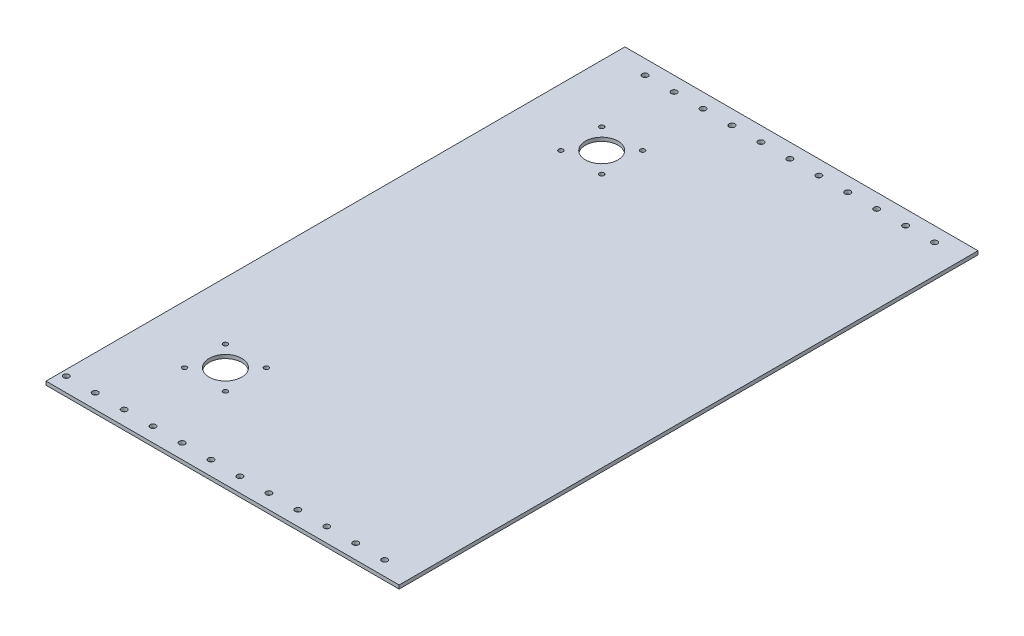
from build123d import *

# Parameters (mm, degrees)
SKETCH1_W               = 406.4
SKETCH1_H               = 508
BOSS_EXTRUDE1_DEPTH     = 3.175
SKETCH2_R               = 14.2875
CUT_EXTRUDE1_DEPTH      = 3.175
SKETCH3_R               = 2.4892
CUT_EXTRUDE2_DEPTH      = 1
CUT_EXTRUDE2_DEPTH_BACK = 4.175
SKETCH4_R               = 2.0193
CUT_EXTRUDE3_DEPTH      = 1
CUT_EXTRUDE3_DEPTH_BACK = 4.175
SKETCH5_W               = 508
SKETCH5_H               = 3.175
CUT_EXTRUDE4_DEPTH      = 96.52


with BuildPart() as part:
    # Sketch1 → Boss-Extrude1 (new body)
    with BuildSketch(Plane(origin=(0, 0, 0), x_dir=(1, 0, 0), z_dir=(0, 1, 0))):
        with Locations((203.2, 254)):
            Rectangle(SKETCH1_W, SKETCH1_H)
    extrude(amount=BOSS_EXTRUDE1_DEPTH)

    # Sketch2 → Cut-Extrude1 (cut)
    with BuildSketch(Plane(origin=(0, 3.175, 0), x_dir=(1, 0, 0), z_dir=(0, 1, 0))):
        with Locations((50.8, 419.1)):
            Circle(SKETCH2_R)
        with Locations((165.1, 419.1)):
            Circle(SKETCH2_R)
        with Locations((50.8, 88.9)):
            Circle(SKETCH2_R)
        with Locations((165.1, 88.9)):
            Circle(SKETCH2_R)
    extrude(amount=-CUT_EXTRUDE1_DEPTH, mode=Mode.SUBTRACT)

    # Sketch3 → Cut-Extrude2 (cut, two sides)
    with BuildSketch(Plane(origin=(0, 3.175, 0), x_dir=(1, 0, 0), z_dir=(0, 1, 0))) as cut_extrude2_sk:
        with Locations((38.1, 12.7)):
            Circle(SKETCH3_R)
        with Locations((63.5, 12.7)):
            Circle(SKETCH3_R)
        with Locations((127, 12.7)):
            Circle(SKETCH3_R)
        with Locations((152.4, 12.7)):
            Circle(SKETCH3_R)
        with Locations((177.8, 12.7)):
            Circle(SKETCH3_R)
        with Locations((203.2, 12.7)):
            Circle(SKETCH3_R)
        with Locations((228.6, 12.7)):
            Circle(SKETCH3_R)
        with Locations((254, 12.7)):
            Circle(SKETCH3_R)
        with Locations((279.4, 12.7)):
            Circle(SKETCH3_R)
        with Locations((304.8, 12.7)):
            Circle(SKETCH3_R)
        with Locations((330.2, 12.7)):
            Circle(SKETCH3_R)
        with Locations((355.6, 12.7)):
            Circle(SKETCH3_R)
        with Locations((381, 12.7)):
            Circle(SKETCH3_R)
        with Locations((381, 495.3)):
            Circle(SKETCH3_R)
        with Locations((355.6, 495.3)):
            Circle(SKETCH3_R)
        with Locations((330.2, 495.3)):
            Circle(SKETCH3_R)
        with Locations((304.8, 495.3)):
            Circle(SKETCH3_R)
        with Locations((279.4, 495.3)):
            Circle(SKETCH3_R)
        with Locations((254, 495.3)):
            Circle(SKETCH3_R)
        with Locations((228.6, 495.3)):
            Circle(SKETCH3_R)
        with Locations((203.2, 495.3)):
            Circle(SKETCH3_R)
        with Locations((177.8, 495.3)):
            Circle(SKETCH3_R)
        with Locations((152.4, 495.3)):
            Circle(SKETCH3_R)
        with Locations((127, 495.3)):
            Circle(SKETCH3_R)
        with Locations((63.5, 495.3)):
            Circle(SKETCH3_R)
        with Locations((38.1, 495.3)):
            Circle(SKETCH3_R)
        with Locations((101.6, 12.7)):
            Circle(SKETCH3_R)
    extrude(amount=CUT_EXTRUDE2_DEPTH, mode=Mode.SUBTRACT)
    extrude(cut_extrude2_sk.sketch, amount=-CUT_EXTRUDE2_DEPTH_BACK, mode=Mode.SUBTRACT)

    # Sketch4 → Cut-Extrude3 (cut, two sides)
    with BuildSketch(Plane(origin=(0, 3.175, 0), x_dir=(1, 0, 0), z_dir=(0, 1, 0))) as cut_extrude3_sk:
        with Locations((76.2, 419.1)):
            Circle(SKETCH4_R)
        with Locations((25.4, 419.1)):
            Circle(SKETCH4_R)
        with Locations((38.1, 441.097045256)):
            Circle(SKETCH4_R)
        with Locations((63.5, 441.097045256)):
            Circle(SKETCH4_R)
        with Locations((63.5, 397.102954744)):
            Circle(SKETCH4_R)
        with Locations((38.1, 397.102954744)):
            Circle(SKETCH4_R)
        with Locations((147.139487788, 437.060512212)):
            Circle(SKETCH4_R)
        with Locations((183.060512212, 437.060512212)):
            Circle(SKETCH4_R)
        with Locations((183.060512212, 401.139487788)):
            Circle(SKETCH4_R)
        with Locations((147.139487788, 401.139487788)):
            Circle(SKETCH4_R)
        with Locations((147.139487788, 106.860512212)):
            Circle(SKETCH4_R)
        with Locations((183.060512212, 106.860512212)):
            Circle(SKETCH4_R)
        with Locations((183.060512212, 70.939487788)):
            Circle(SKETCH4_R)
        with Locations((147.139487788, 70.939487788)):
            Circle(SKETCH4_R)
        with Locations((38.1, 110.897045256)):
            Circle(SKETCH4_R)
        with Locations((63.5, 110.897045256)):
            Circle(SKETCH4_R)
        with Locations((63.5, 66.902954744)):
            Circle(SKETCH4_R)
        with Locations((38.1, 66.902954744)):
            Circle(SKETCH4_R)
        with Locations((25.4, 88.9)):
            Circle(SKETCH4_R)
        with Locations((76.2, 88.9)):
            Circle(SKETCH4_R)
    extrude(amount=CUT_EXTRUDE3_DEPTH, mode=Mode.SUBTRACT)
    extrude(cut_extrude3_sk.sketch, amount=-CUT_EXTRUDE3_DEPTH_BACK, mode=Mode.SUBTRACT)

    # Sketch5 → Cut-Extrude4 (cut)
    with BuildSketch(Plane.ZY):
        with Locations((-254, 1.5875)):
            Rectangle(SKETCH5_W, SKETCH5_H)
    extrude(amount=-CUT_EXTRUDE4_DEPTH, mode=Mode.SUBTRACT)


solid = part.part
